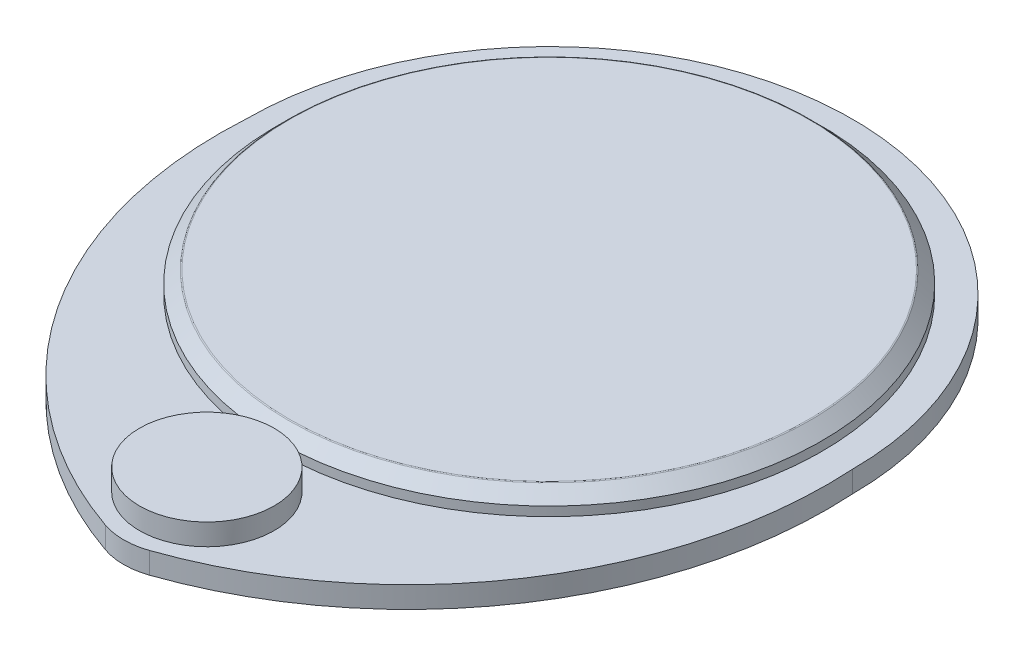
from build123d import *

# Parameters (mm, degrees)
SKETCH1_R           = 44.5
BOSS_EXTRUDE1_DEPTH = 3.5
CHAMFER1_SIZE       = 2
SKETCH2_R           = 49.5
BOSS_EXTRUDE2_DEPTH = 3.5
BOSS_EXTRUDE3_DEPTH = 3.5
SKETCH7_R           = 10.991686932
BOSS_EXTRUDE4_DEPTH = 3.5
FILLET1_R           = 11
FILLET2_R           = 0.25


with BuildPart() as part:
    # Sketch1 → Boss-Extrude1 (new body)
    with BuildSketch(Plane(origin=(0, 0, 0), x_dir=(1, 0, 0), z_dir=(0, 1, 0))):
        Circle(SKETCH1_R)
    extrude(amount=BOSS_EXTRUDE1_DEPTH)

    # Chamfer1
    chamfer1_edges = [part.edges().sort_by_distance(p)[0] for p in [
        (-44.5, 3.5, 0),
    ]]
    chamfer(chamfer1_edges, length=CHAMFER1_SIZE)

    # Sketch2 → Boss-Extrude2 (add)
    with BuildSketch(Plane.XZ):
        Circle(SKETCH2_R)
    extrude(amount=BOSS_EXTRUDE2_DEPTH)

    # Sketch3 → Boss-Extrude3 (add)
    with BuildSketch(Plane(origin=(0, 0, 0), x_dir=(1, 0, 0), z_dir=(0, 1, 0))):
        with BuildLine():
            ThreePointArc((49.5, 0), (37.061785537, -43.706191201), (0, -70))
            ThreePointArc((0, -70), (-37.061785537, -43.706191201), (-49.5, 0))
            ThreePointArc((-49.5, 0), (0, -49.5), (49.5, 0))
        make_face()
    extrude(amount=-BOSS_EXTRUDE3_DEPTH)

    # Sketch7 → Boss-Extrude4 (add)
    with BuildSketch(Plane(origin=(0, 0, 0), x_dir=(1, 0, 0), z_dir=(0, 1, 0))):
        with Locations((0, -55.892027532)):
            Circle(SKETCH7_R)
    extrude(amount=BOSS_EXTRUDE4_DEPTH)

    # Fillet1
    fillet1_edges = [part.edges().sort_by_distance(p)[0] for p in [
        (0, -1.75, 70),
    ]]
    fillet(fillet1_edges, radius=FILLET1_R)

    # Fillet2
    fillet2_edges = [part.edges().sort_by_distance(p)[0] for p in [
        (-42.5, 3.5, 0),
    ]]
    fillet(fillet2_edges, radius=FILLET2_R)


solid = part.part
